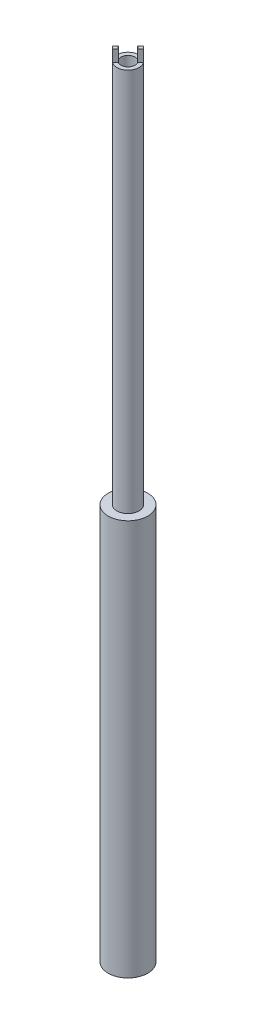
from build123d import *

# Parameters (mm, degrees)
SKETCH1_R           = 1.389
SKETCH1_R_2         = 0.889
BOSS_EXTRUDE1_DEPTH = 100
SKETCH2_R           = 2.5
BOSS_EXTRUDE2_DEPTH = 50
CUT_EXTRUDE1_DEPTH  = 1.5


with BuildPart() as part:
    # Sketch1 → Boss-Extrude1 (new body)
    with BuildSketch(Plane(origin=(0, 0, 0), x_dir=(1, 0, 0), z_dir=(0, 1, 0))):
        Circle(SKETCH1_R)
        Circle(SKETCH1_R_2, mode=Mode.SUBTRACT)
    extrude(amount=BOSS_EXTRUDE1_DEPTH)

    # Sketch2 → Boss-Extrude2 (add)
    with BuildSketch(Plane(origin=(0, 0, 0), x_dir=(1, 0, 0), z_dir=(0, 1, 0))):
        Circle(SKETCH2_R)
    extrude(amount=BOSS_EXTRUDE2_DEPTH)

    # Sketch3 → Cut-Extrude1 (cut)
    with BuildSketch(Plane(origin=(0, 100, 0), x_dir=(1, 0, 0), z_dir=(0, 1, 0))):
        Polygon((-2.121320344, 0), (0, 2.121320344), (0.901561146, 1.219759198), (-1.219759198, -0.901561146), align=None)
        Polygon((2.121320344, 0), (0, -2.121320344), (-0.901561146, -1.219759198), (1.219759198, 0.901561146), align=None)
    extrude(amount=-CUT_EXTRUDE1_DEPTH, mode=Mode.SUBTRACT)


solid = part.part
